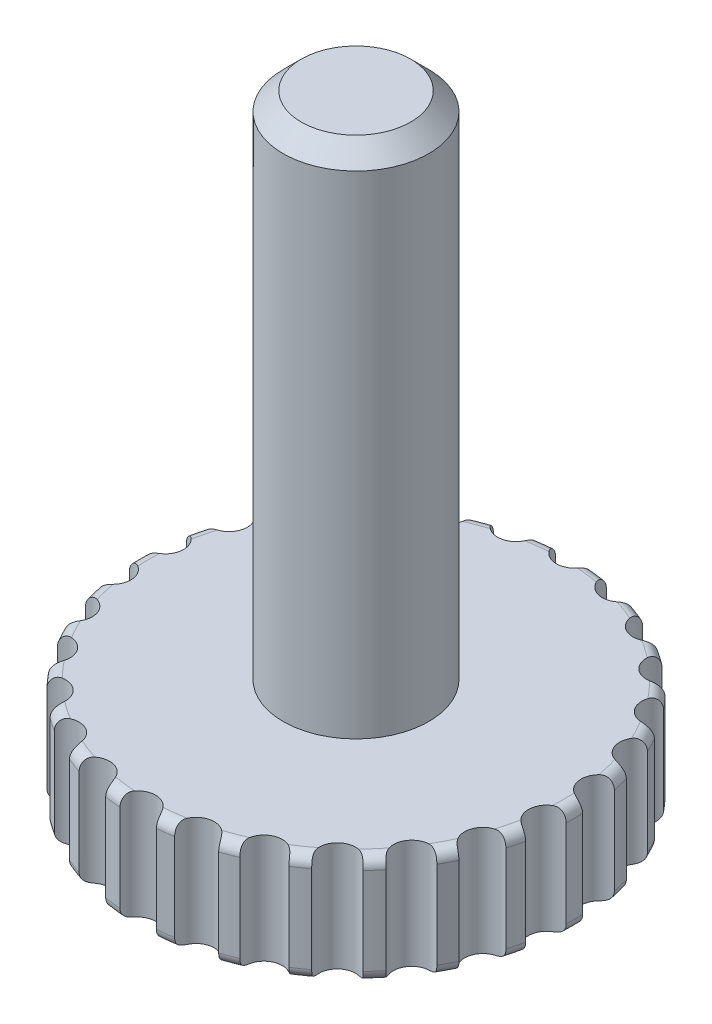
from build123d import *

# Parameters (mm, degrees)
CHAMFER1_SIZE      = 0.5
FILLET1_R          = 0.3
CUT_EXTRUDE1_START = -3
SKETCH2_R          = 0.5
CUT_EXTRUDE1_DEPTH = 3


with BuildPart() as part:
    # Sketch1 → Revolve1 (revolve)
    with BuildSketch(Plane.XY):
        Polygon((0, 17), (-2, 17), (-2, 3), (-6, 3), (-6, 0), (0, 0), align=None)
    revolve(axis=Axis((0, 17, 0), (0, -1, 0)))

    # Chamfer1
    chamfer1_edges = [part.edges().sort_by_distance(p)[0] for p in [
        (2, 17, 0),
    ]]
    chamfer(chamfer1_edges, length=CHAMFER1_SIZE)

    # Fillet1
    fillet1_edges = [part.edges().sort_by_distance(p)[0] for p in [
        (6, 0, 0),
        (6, 3, 0),
    ]]
    fillet(fillet1_edges, radius=FILLET1_R)

    # Sketch2 → Cut-Extrude1 (cut)
    with BuildSketch(Plane(origin=(0, 0, 0), x_dir=(-1, 0, 0), z_dir=(0, -1, 0)).offset(CUT_EXTRUDE1_START)):
        with Locations((0, -6)):
            Circle(SKETCH2_R)
        with Locations((-1.435893986, -5.825650905)):
            Circle(SKETCH2_R)
        with Locations((-2.788339032, -5.312736154)):
            Circle(SKETCH2_R)
        with Locations((-3.978735949, -4.491064489)):
            Circle(SKETCH2_R)
        with Locations((-4.937903195, -3.40838848)):
            Circle(SKETCH2_R)
        with Locations((-5.610097456, -2.127629322)):
            Circle(SKETCH2_R)
        with Locations((-5.956253245, -0.723220082)):
            Circle(SKETCH2_R)
        with Locations((-5.956253245, 0.723220082)):
            Circle(SKETCH2_R)
        with Locations((-5.610097456, 2.127629322)):
            Circle(SKETCH2_R)
        with Locations((-4.937903195, 3.40838848)):
            Circle(SKETCH2_R)
        with Locations((-3.978735949, 4.491064489)):
            Circle(SKETCH2_R)
        with Locations((-2.788339032, 5.312736154)):
            Circle(SKETCH2_R)
        with Locations((-1.435893986, 5.825650905)):
            Circle(SKETCH2_R)
        with Locations((0, 6)):
            Circle(SKETCH2_R)
        with Locations((1.435893986, 5.825650905)):
            Circle(SKETCH2_R)
        with Locations((2.788339032, 5.312736154)):
            Circle(SKETCH2_R)
        with Locations((3.978735949, 4.491064489)):
            Circle(SKETCH2_R)
        with Locations((4.937903195, 3.40838848)):
            Circle(SKETCH2_R)
        with Locations((5.610097456, 2.127629322)):
            Circle(SKETCH2_R)
        with Locations((5.956253245, 0.723220082)):
            Circle(SKETCH2_R)
        with Locations((5.956253245, -0.723220082)):
            Circle(SKETCH2_R)
        with Locations((5.610097456, -2.127629322)):
            Circle(SKETCH2_R)
        with Locations((4.937903195, -3.40838848)):
            Circle(SKETCH2_R)
        with Locations((3.978735949, -4.491064489)):
            Circle(SKETCH2_R)
        with Locations((2.788339032, -5.312736154)):
            Circle(SKETCH2_R)
        with Locations((1.435893986, -5.825650905)):
            Circle(SKETCH2_R)
    extrude(amount=CUT_EXTRUDE1_DEPTH, mode=Mode.SUBTRACT)


solid = part.part
